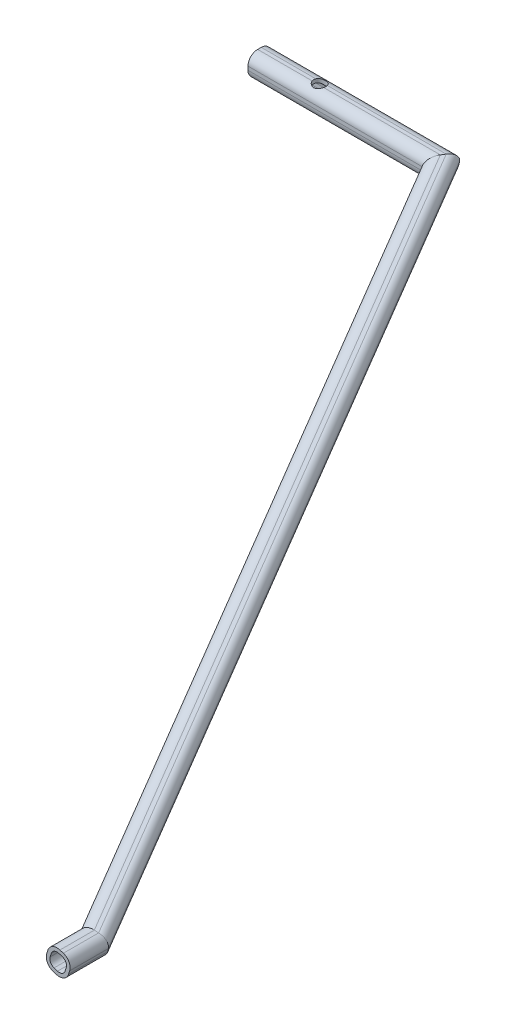
from build123d import *

# Parameters (mm, degrees)
SKETCH21_R              = 5
CUT_EXTRUDE3_DEPTH      = 10.5
CUT_EXTRUDE3_DEPTH_BACK = 210.883244548


with BuildPart() as part:
    # Sweep-Thin3: sweep along a curve in space
    with BuildLine() as sweep_thin3_path:
        Line((0, 0, 0), (150, 0, 0))
        Line((150, 0, 0), (363.169892788, -200, 500))
        Line((363.169892788, -200, 500), (363.169892788, -200, 530))
    # Sketch2 → Sweep-Thin3 (sweep)
    with BuildSketch(Plane(origin=(0, 0, 0), x_dir=(0, 0, -1), z_dir=(1, 0, 0))):
        with BuildLine():
            Line((1.5, 9.5), (-1.5, 9.5))
            ThreePointArc((-1.5, 9.5), (-7.156854249, 7.156854249), (-9.5, 1.5))
            Line((-9.5, 1.5), (-9.5, -1.5))
            ThreePointArc((-9.5, -1.5), (-7.156854249, -7.156854249), (-1.5, -9.5))
            Line((-1.5, -9.5), (1.5, -9.5))
            ThreePointArc((1.5, -9.5), (7.156854249, -7.156854249), (9.5, -1.5))
            Line((9.5, -1.5), (9.5, 1.5))
            ThreePointArc((9.5, 1.5), (7.156854249, 7.156854249), (1.5, 9.5))
        make_face()
        with BuildLine():
            Line((1.5, 6.5), (-1.5, 6.5))
            ThreePointArc((-1.5, 6.5), (-5.035533906, 5.035533906), (-6.5, 1.5))
            Line((-6.5, 1.5), (-6.5, -1.5))
            ThreePointArc((-6.5, -1.5), (-5.035533906, -5.035533906), (-1.5, -6.5))
            Line((-1.5, -6.5), (1.5, -6.5))
            ThreePointArc((1.5, -6.5), (5.035533906, -5.035533906), (6.5, -1.5))
            Line((6.5, -1.5), (6.5, 1.5))
            ThreePointArc((6.5, 1.5), (5.035533906, 5.035533906), (1.5, 6.5))
        make_face(mode=Mode.SUBTRACT)
    sweep(path=sweep_thin3_path.line, transition=Transition.RIGHT)

    # Sketch21 → Cut-Extrude3 (cut, two sides)
    with BuildSketch(Plane(origin=(0, 0, 0), x_dir=(1, 0, 0), z_dir=(0, 1, 0))) as cut_extrude3_sk:
        with Locations((50, 0)):
            Circle(SKETCH21_R)
    extrude(amount=CUT_EXTRUDE3_DEPTH, mode=Mode.SUBTRACT)
    extrude(cut_extrude3_sk.sketch, amount=-CUT_EXTRUDE3_DEPTH_BACK, mode=Mode.SUBTRACT)


solid = part.part
